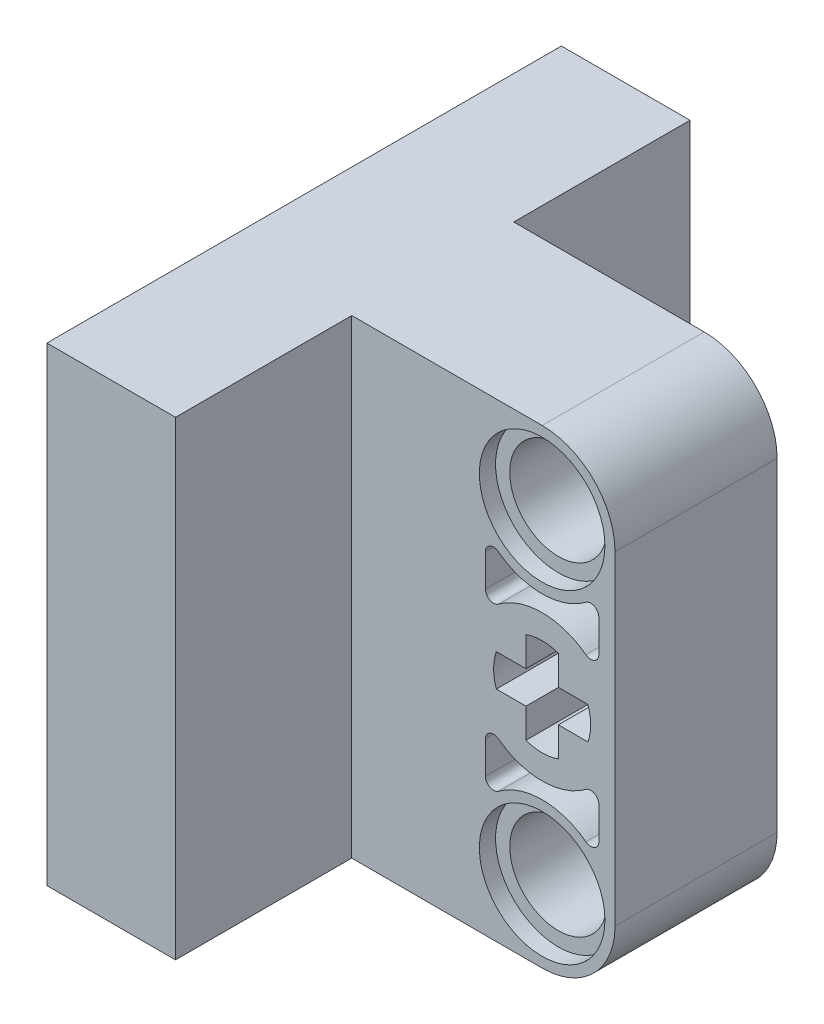
from build123d import *

# Parameters (mm, degrees)
BOSS_EXTRUDE1_DEPTH = 8
SKETCH15_W          = 8
SKETCH15_H          = 23.2
BOSS_EXTRUDE2_DEPTH = 15.75
CUT_EXTRUDE2_DEPTH  = 3.1
CUT_EXTRUDE4_DEPTH  = 3.1
CUT_EXTRUDE6_DEPTH  = 3.1
CUT_EXTRUDE7_DEPTH  = 3.1
CUT_EXTRUDE12_DEPTH = 9
SKETCH18_W          = 6.35
SKETCH18_H          = 23.2
BOSS_EXTRUDE3_DEPTH = 12.7


with BuildPart() as part:
    # Sketch1 → Boss-Extrude1 (new body)
    with BuildSketch(Plane.XY.offset(4)):
        with BuildLine():
            Line((-3.6, 0), (-3.6, -16))
            ThreePointArc((-3.6, -16), (0, -19.6), (3.6, -16))
            Line((3.6, -16), (3.6, 0))
            ThreePointArc((3.6, 0), (0, 3.6), (-3.6, 0))
        make_face()
    extrude(amount=-BOSS_EXTRUDE1_DEPTH)

    # Sketch15 → Boss-Extrude2 (add)
    with BuildSketch(Plane.ZY):
        with Locations((0, -8)):
            Rectangle(SKETCH15_W, SKETCH15_H)
    extrude(amount=BOSS_EXTRUDE2_DEPTH)

    # Sketch3 → Cut-Extrude2 (cut)
    with BuildSketch(Plane.XY.offset(4)):
        with BuildLine():
            Line((2.8, -4.8), (2.8, -3.2))
            ThreePointArc((2.8, -3.2), (2.578885438, -2.842229124), (2.16, -2.88))
            ThreePointArc((2.16, -2.88), (0, -3.6), (-2.16, -2.88))
            ThreePointArc((-2.16, -2.88), (-2.578885438, -2.842229124), (-2.8, -3.2))
            Line((-2.8, -3.2), (-2.8, -4.8))
            ThreePointArc((-2.8, -4.8), (-2.578885438, -5.157770876), (-2.16, -5.12))
            ThreePointArc((-2.16, -5.12), (0, -4.4), (2.16, -5.12))
            ThreePointArc((2.16, -5.12), (2.578885438, -5.157770876), (2.8, -4.8))
        make_face()
    extrude(amount=-CUT_EXTRUDE2_DEPTH, mode=Mode.SUBTRACT)

    # Sketch5 → Cut-Extrude4 (cut)
    with BuildSketch(Plane.XY.offset(4)):
        with BuildLine():
            Line((2.8, -12.8), (2.8, -11.2))
            ThreePointArc((2.8, -11.2), (2.578885438, -10.842229124), (2.16, -10.88))
            ThreePointArc((2.16, -10.88), (0, -11.6), (-2.16, -10.88))
            ThreePointArc((-2.16, -10.88), (-2.578885438, -10.842229124), (-2.8, -11.2))
            Line((-2.8, -11.2), (-2.8, -12.8))
            ThreePointArc((-2.8, -12.8), (-2.578885438, -13.157770876), (-2.16, -13.12))
            ThreePointArc((-2.16, -13.12), (0, -12.4), (2.16, -13.12))
            ThreePointArc((2.16, -13.12), (2.578885438, -13.157770876), (2.8, -12.8))
        make_face()
    extrude(amount=-CUT_EXTRUDE4_DEPTH, mode=Mode.SUBTRACT)

    # Sketch7 → Cut-Extrude6 (cut)
    with BuildSketch(Plane(origin=(0, 0, -4), x_dir=(-1, 0, 0), z_dir=(0, 0, -1))):
        with BuildLine():
            Line((2.8, -4.8), (2.8, -3.2))
            ThreePointArc((2.8, -3.2), (2.578885438, -2.842229124), (2.16, -2.88))
            ThreePointArc((2.16, -2.88), (0, -3.6), (-2.16, -2.88))
            ThreePointArc((-2.16, -2.88), (-2.578885438, -2.842229124), (-2.8, -3.2))
            Line((-2.8, -3.2), (-2.8, -4.8))
            ThreePointArc((-2.8, -4.8), (-2.578885438, -5.157770876), (-2.16, -5.12))
            ThreePointArc((-2.16, -5.12), (0, -4.4), (2.16, -5.12))
            ThreePointArc((2.16, -5.12), (2.578885438, -5.157770876), (2.8, -4.8))
        make_face()
    extrude(amount=-CUT_EXTRUDE6_DEPTH, mode=Mode.SUBTRACT)

    # Sketch8 → Cut-Extrude7 (cut)
    with BuildSketch(Plane(origin=(0, 0, -4), x_dir=(-1, 0, 0), z_dir=(0, 0, -1))):
        with BuildLine():
            Line((-2.8, -11.2), (-2.8, -12.8))
            ThreePointArc((-2.8, -12.8), (-2.578885438, -13.157770876), (-2.16, -13.12))
            ThreePointArc((-2.16, -13.12), (0, -12.4), (2.16, -13.12))
            ThreePointArc((2.16, -13.12), (2.578885438, -13.157770876), (2.8, -12.8))
            Line((2.8, -12.8), (2.8, -11.2))
            ThreePointArc((2.8, -11.2), (2.578885438, -10.842229124), (2.16, -10.88))
            ThreePointArc((2.16, -10.88), (0, -11.6), (-2.16, -10.88))
            ThreePointArc((-2.16, -10.88), (-2.578885438, -10.842229124), (-2.8, -11.2))
        make_face()
    extrude(amount=-CUT_EXTRUDE7_DEPTH, mode=Mode.SUBTRACT)

    # Sketch10 → Cut-Revolve1 (revolve, cut)
    with BuildSketch(Plane(origin=(0, -16, 0), x_dir=(1, 0, 0), z_dir=(0, 1, 0))):
        Polygon((3.1, 4), (0, 4), (0, -4), (3.1, -4), (3.1, -3.2), (2.4, -3.2), (2.4, 3.2), (3.1, 3.2), align=None)
    revolve(axis=Axis((0, -16, -4), (0, 0, 1)), mode=Mode.SUBTRACT)

    # Sketch13 → Cut-Revolve4 (revolve, cut)
    with BuildSketch(Plane(origin=(0, 0, 0), x_dir=(1, 0, 0), z_dir=(0, 1, 0))):
        Polygon((3.1, 4), (0, 4), (0, -4), (3.1, -4), (3.1, -3.2), (2.4, -3.2), (2.4, 3.2), (3.1, 3.2), align=None)
    revolve(axis=Axis((0, 0, -4), (0, 0, 1)), mode=Mode.SUBTRACT)

    # Sketch14 → Cut-Extrude12 (cut, through all)
    with BuildSketch(Plane.XY.offset(4)):
        with BuildLine():
            ThreePointArc((-2.26, -8.8), (-2.3972583, -8), (-2.26, -7.2))
            Line((-2.26, -7.2), (-0.8, -7.2))
            Line((-0.8, -7.2), (-0.8, -5.74))
            ThreePointArc((-0.8, -5.74), (0, -5.6027417), (0.8, -5.74))
            Line((0.8, -5.74), (0.8, -7.2))
            Line((0.8, -7.2), (2.26, -7.2))
            ThreePointArc((2.26, -7.2), (2.3972583, -8), (2.26, -8.8))
            Line((2.26, -8.8), (0.8, -8.8))
            Line((0.8, -8.8), (0.8, -10.26))
            ThreePointArc((0.8, -10.26), (0, -10.3972583), (-0.8, -10.26))
            Line((-0.8, -10.26), (-0.8, -8.8))
            Line((-0.8, -8.8), (-2.26, -8.8))
        make_face()
    extrude(amount=-CUT_EXTRUDE12_DEPTH, mode=Mode.SUBTRACT)

    # Sketch18 → Boss-Extrude3 (add, symmetric)
    with BuildSketch(Plane(origin=(0, 0, 0), x_dir=(-1, 0, 0), z_dir=(0, 0, -1))):
        with Locations((12.575, -8)):
            Rectangle(SKETCH18_W, SKETCH18_H)
    extrude(amount=BOSS_EXTRUDE3_DEPTH, both=True)


solid = part.part
